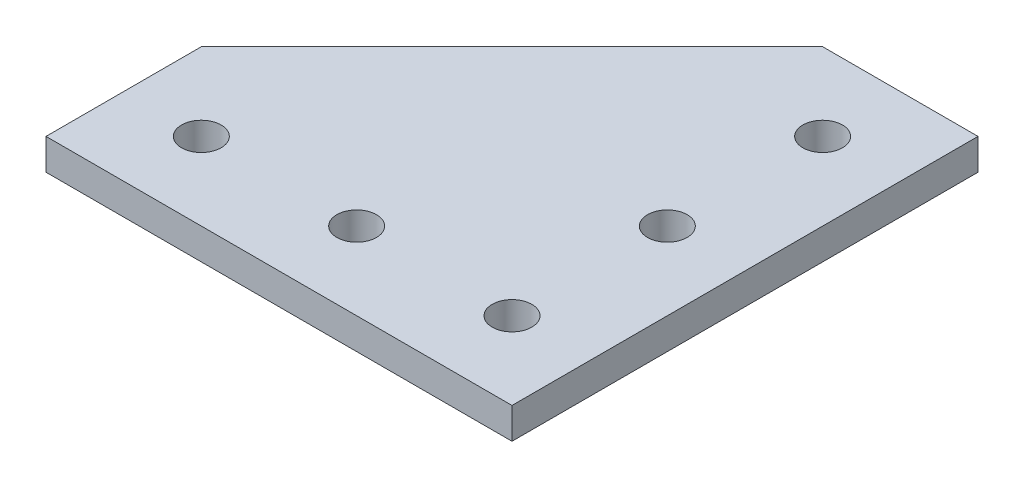
from build123d import *

# Parameters (mm, degrees)
SKETCH1_R           = 2.55
BOSS_EXTRUDE1_DEPTH = 4


with BuildPart() as part:
    # Sketch1 → Boss-Extrude1 (new body)
    with BuildSketch(Plane(origin=(0, 0, 0), x_dir=(1, 0, 0), z_dir=(0, 1, 0))):
        Polygon((10, -10), (-50, -10), (-50, 10), (-10, 50), (10, 50), align=None)
        with Locations((-20, 0)):
            Circle(SKETCH1_R, mode=Mode.SUBTRACT)
        with Locations((-40, 0)):
            Circle(SKETCH1_R, mode=Mode.SUBTRACT)
        Circle(SKETCH1_R, mode=Mode.SUBTRACT)
        with Locations((0, 20)):
            Circle(SKETCH1_R, mode=Mode.SUBTRACT)
        with Locations((0, 40)):
            Circle(SKETCH1_R, mode=Mode.SUBTRACT)
    extrude(amount=BOSS_EXTRUDE1_DEPTH)


solid = part.part
